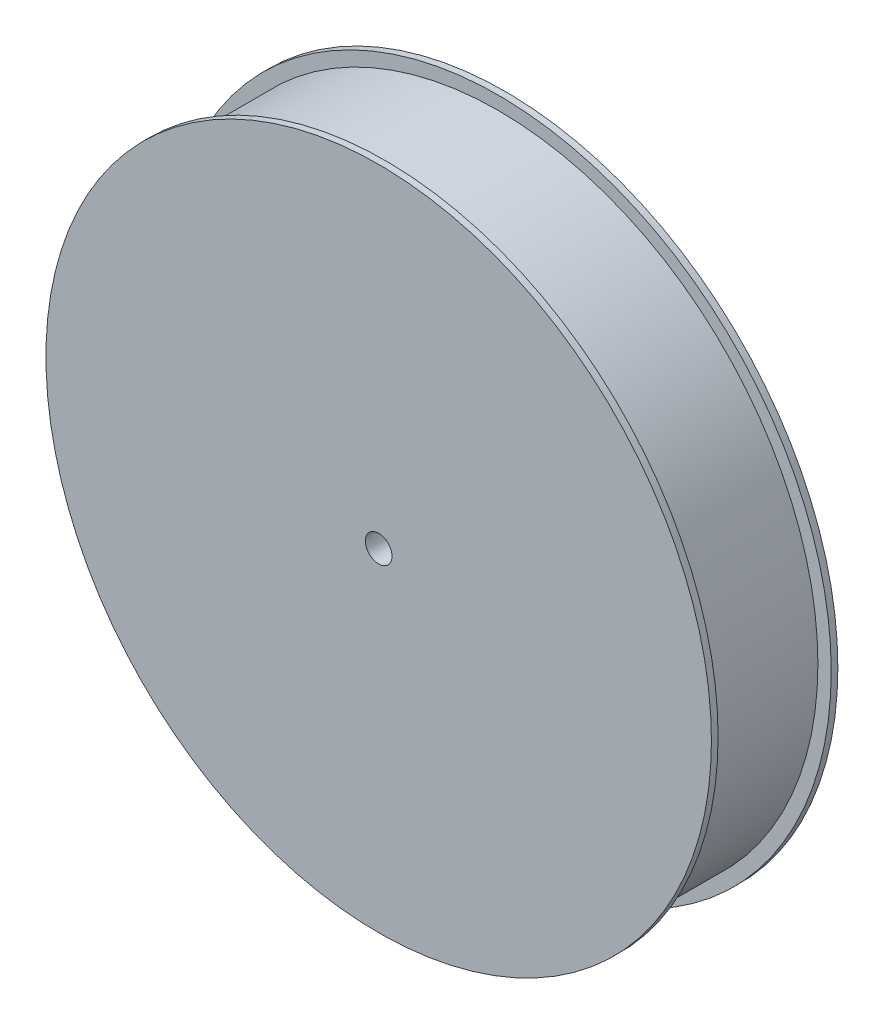
from build123d import *

# Parameters (mm, degrees)
INNER_R             = 76.2
BOSS_EXTRUDE1_DEPTH = 13.49375
RIM_R               = 79.375
BOSS_EXTRUDE2_DEPTH = 1.5875
HOLE_R              = 3.175
CUT_EXTRUDE1_DEPTH  = 31.1625


with BuildPart() as part:
    # Inner → Boss-Extrude1 (new body)
    with BuildSketch(Plane.XY):
        Circle(INNER_R)
    extrude(amount=BOSS_EXTRUDE1_DEPTH)

    # Rim → Boss-Extrude2 (add)
    with BuildSketch(Plane.XY.offset(13.49375)):
        Circle(RIM_R)
    extrude(amount=BOSS_EXTRUDE2_DEPTH)

    # Mirror1: part across plane


with BuildPart() as part_1:
    add(part.part)
    add(part.part.mirror(Plane.XY))

    # Hole → Cut-Extrude1 (cut, through all)
    with BuildSketch(Plane.XY.offset(15.08125)):
        Circle(HOLE_R)
    extrude(amount=-CUT_EXTRUDE1_DEPTH, mode=Mode.SUBTRACT)


solid = part_1.part
